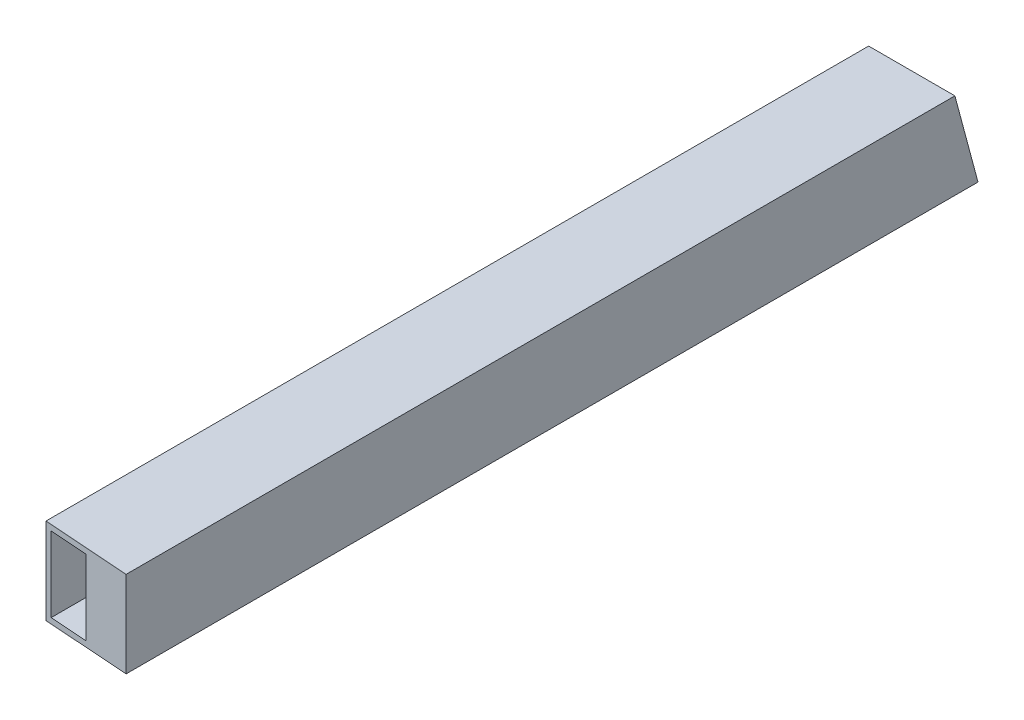
from build123d import *

# Parameters (mm, degrees)
SKETCH1_W           = 25.4
SKETCH1_H           = 25.4
SKETCH1_W_2         = 22.098
SKETCH1_H_2         = 22.098
BOSS_EXTRUDE1_DEPTH = 250
SKETCH4_W           = 25.4
SKETCH4_H           = 25.4
BOSS_EXTRUDE2_DEPTH = 25.4
CUT_EXTRUDE1_DEPTH  = 165.021579309
CUT_EXTRUDE2_DEPTH  = 26.4


with BuildPart() as part:
    # Sketch1 → Boss-Extrude1 (new body)
    with BuildSketch(Plane.XY):
        Rectangle(SKETCH1_W, SKETCH1_H)
        Rectangle(SKETCH1_W_2, SKETCH1_H_2, mode=Mode.SUBTRACT)
    extrude(amount=BOSS_EXTRUDE1_DEPTH)

    # Sketch4 → Boss-Extrude2 (add)
    with BuildSketch(Plane.XY.offset(250)):
        Rectangle(SKETCH4_W, SKETCH4_H)
    extrude(amount=BOSS_EXTRUDE2_DEPTH)

    # Sketch5 → Cut-Extrude1 (cut, through all)
    with BuildSketch(Plane(origin=(-589.319373916, -151.321579309, 111.97168159), x_dir=(0, 0, -1), z_dir=(0, 1, 0))):
        Polygon((-140.246306665, -620.299815752), (-213.016787638, -571.728098704), (-135.810330154, -558.33893208), align=None)
    extrude(amount=CUT_EXTRUDE1_DEPTH, mode=Mode.SUBTRACT)

    # Sketch6 → Cut-Extrude2 (cut, through all)
    with BuildSketch(Plane(origin=(12.7, 0, 0), x_dir=(0, 0, -1), z_dir=(1, 0, 0))):
        Polygon((0, -12.7), (-11.495760494, 30.202762236), (0, 24.093064972), align=None)
    extrude(amount=-CUT_EXTRUDE2_DEPTH, mode=Mode.SUBTRACT)


solid = part.part
